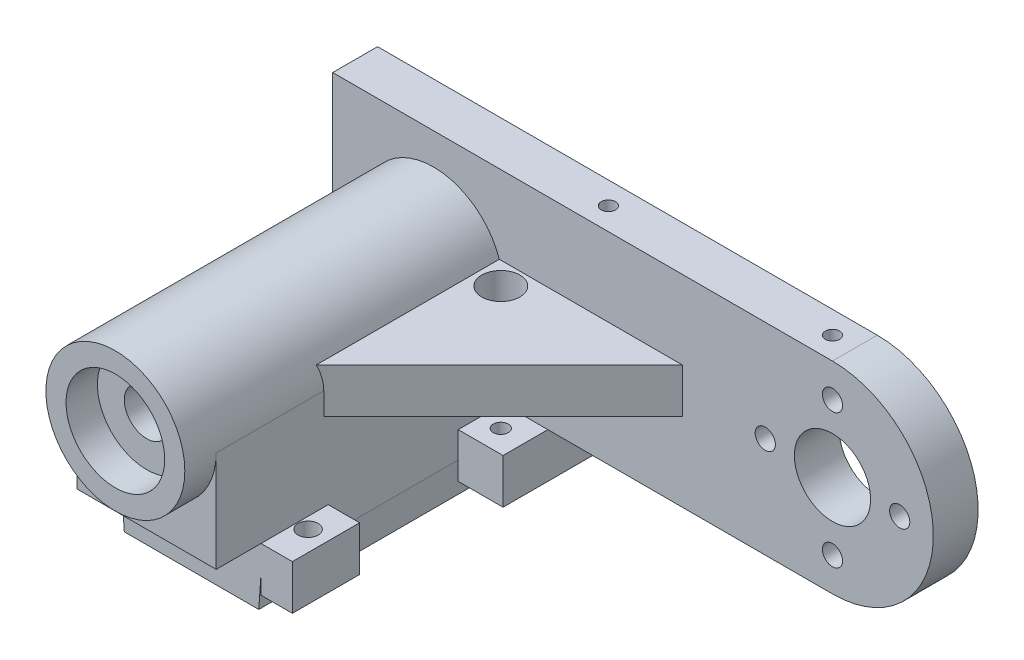
from build123d import *

# Parameters (mm, degrees)
SKETCH1_W                = 26
SKETCH1_H                = 53
SKETCH1_W_2              = 20
SKETCH1_H_2              = 10
BOSS_EXTRUDE1_DEPTH      = 5
SKETCH2_W                = 31
SKETCH2_H                = 59
SKETCH2_W_2              = 26
SKETCH2_H_2              = 53
BOSS_EXTRUDE2_DEPTH      = 10
SKETCH3_W                = 31
SKETCH3_H                = 59
BOSS_EXTRUDE3_DEPTH      = 3
CHAMFER1_SIZE            = 0.5
CHAMFER1_SIZE2           = 7.150333128
SKETCH10_W               = 7
SKETCH10_H               = 15
SKETCH10_R               = 2.25
BOSS_EXTRUDE7_DEPTH      = 10
SKETCH11_W               = 7
SKETCH11_H               = 3
CUT_EXTRUDE4_DEPTH       = 10
CHAMFER2_SIZE            = 2
CHAMFER2_SIZE2           = 4.100607683
BOSS_EXTRUDE8_REACH      = 69.567
SKETCH12_W               = 10
SKETCH12_H               = 15
SKETCH12_R               = 1.676379865
BOSS_EXTRUDE9_START      = -56
SKETCH15_R               = 8.5
SKETCH15_R_2             = 2.25
SKETCH15_R_3             = 11
BOSS_EXTRUDE9_DEPTH      = 5
BOSS_EXTRUDE9_DEPTH_BACK = 5
SKETCH16_R               = 2.25
SKETCH16_R_2             = 8.5
SKETCH16_R_3             = 5
BOSS_EXTRUDE10_DEPTH     = 2
SKETCH17_R               = 5
BOSS_EXTRUDE11_DEPTH     = 64
RIB2_REACH               = 123.175
SKETCH20_WALL_W          = 300.919527638
SKETCH20_WALL_H          = 10
BOSS_EXTRUDE12_DEPTH     = 5
SKETCH22_R               = 15.5
SKETCH22_R_2             = 11
BOSS_EXTRUDE13_DEPTH     = 7
SKETCH23_R               = 4.25
CUT_EXTRUDE5_DEPTH       = 29
SKETCH24_R               = 1.6
CUT_EXTRUDE6_DEPTH       = 8
SKETCH25_R               = 1.6
CUT_EXTRUDE7_DEPTH       = 8


with BuildPart() as part:
    # Sketch1 → Boss-Extrude1 (new body)
    with BuildSketch(Plane(origin=(0, 0, 0), x_dir=(1, 0, 0), z_dir=(0, 1, 0))):
        with Locations((-13, 26.5)):
            Rectangle(SKETCH1_W, SKETCH1_H)
        with Locations((-13, 27)):
            Rectangle(SKETCH1_W_2, SKETCH1_H_2, mode=Mode.SUBTRACT)
        with Locations((-13, 43)):
            Rectangle(SKETCH1_W_2, SKETCH1_H_2, mode=Mode.SUBTRACT)
        with Locations((-13, 11)):
            Rectangle(SKETCH1_W_2, SKETCH1_H_2, mode=Mode.SUBTRACT)
    extrude(amount=BOSS_EXTRUDE1_DEPTH)

    # Sketch2 → Boss-Extrude2 (add)
    with BuildSketch(Plane(origin=(0, 5, 0), x_dir=(1, 0, 0), z_dir=(0, 1, 0))):
        with Locations((-13, 26.5)):
            Rectangle(SKETCH2_W, SKETCH2_H)
        with Locations((-13, 26.5)):
            Rectangle(SKETCH2_W_2, SKETCH2_H_2, mode=Mode.SUBTRACT)
    extrude(amount=-BOSS_EXTRUDE2_DEPTH)

    # Sketch3 → Boss-Extrude3 (add)
    with BuildSketch(Plane(origin=(0, 5, 0), x_dir=(1, 0, 0), z_dir=(0, 1, 0))):
        with Locations((-13, 26.5)):
            Rectangle(SKETCH3_W, SKETCH3_H)
    extrude(amount=BOSS_EXTRUDE3_DEPTH)

    # Chamfer1
    chamfer1_edges = [part.edges().sort_by_distance(p)[0] for p in [
        (-28.5, -5, -26.5),
        (2.5, -5, -26.5),
    ]]
    chamfer1_side = [part.faces().sort_by_distance(p)[0] for p in [
        (-13, -5, -55.333516692),
    ]]
    chamfer(chamfer1_edges, length=CHAMFER1_SIZE, length2=CHAMFER1_SIZE2, reference=chamfer1_side[0])

    # Sketch10 → Boss-Extrude7 (add)
    with BuildSketch(Plane(origin=(0, 8, 0), x_dir=(1, 0, 0), z_dir=(0, 1, 0))):
        with Locations((6, 4.5)):
            Rectangle(SKETCH10_W, SKETCH10_H)
        with Locations(Location((5, 5, 0), (0, 0, 270))):
            Circle(SKETCH10_R, mode=Mode.SUBTRACT)
        with Locations((-32, 4.5)):
            Rectangle(SKETCH10_W, SKETCH10_H)
        with Locations(Location((-31, 5, 0), (0, 0, 90))):
            Circle(SKETCH10_R, mode=Mode.SUBTRACT)
    extrude(amount=-BOSS_EXTRUDE7_DEPTH)

    # Sketch11 → Cut-Extrude4 (cut)
    with BuildSketch(Plane(origin=(0, 8, 0), x_dir=(1, 0, 0), z_dir=(0, 1, 0))):
        with Locations((-32, 10.5)):
            Rectangle(SKETCH11_W, SKETCH11_H)
    extrude(amount=-CUT_EXTRUDE4_DEPTH, mode=Mode.SUBTRACT)

    # Chamfer2
    chamfer2_edges = [part.edges().sort_by_distance(p)[0] for p in [
        (-35.5, 3, -9),
    ]]
    chamfer2_side = [part.faces().sort_by_distance(p)[0] for p in [
        (-35.5, 3, -3),
    ]]
    chamfer(chamfer2_edges, length=CHAMFER2_SIZE, length2=CHAMFER2_SIZE2, reference=chamfer2_side[0])

    # Boss-Extrude8: up to this face of the body (flat: up to its plane)
    boss_extrude8_end = Plane(part.part.faces().sort_by_distance((6, -2, 2.834470546))[0])
    # Sketch12 → Boss-Extrude8 (add, up to the picked face)
    with BuildSketch(Plane(origin=(0, 8, 0), x_dir=(1, 0, 0), z_dir=(0, 1, 0)), mode=Mode.PRIVATE) as boss_extrude8_sk1:
        with Locations((7.5, 48.5)):
            Rectangle(SKETCH12_W, SKETCH12_H)
        with Locations(Location((7, 46, 0), (0, 0, 270))):
            Circle(SKETCH12_R, mode=Mode.SUBTRACT)
    boss_extrude8_tool1 = split(extrude(boss_extrude8_sk1.sketch, amount=-BOSS_EXTRUDE8_REACH, mode=Mode.PRIVATE), bisect_by=boss_extrude8_end, keep=Keep.BOTH, mode=Mode.PRIVATE)
    # Sketch12 → Boss-Extrude8 (add, up to the picked face)
    with BuildSketch(Plane(origin=(0, 8, 0), x_dir=(1, 0, 0), z_dir=(0, 1, 0)), mode=Mode.PRIVATE) as boss_extrude8_sk2:
        with Locations((-33.5, 48.5)):
            Rectangle(SKETCH12_W, SKETCH12_H)
        with Locations(Location((-33, 46, 0), (0, 0, 270))):
            Circle(SKETCH12_R, mode=Mode.SUBTRACT)
    boss_extrude8_tool2 = split(extrude(boss_extrude8_sk2.sketch, amount=-BOSS_EXTRUDE8_REACH, mode=Mode.PRIVATE), bisect_by=boss_extrude8_end, keep=Keep.BOTH, mode=Mode.PRIVATE)
    add(boss_extrude8_tool1.solids().sort_by(Axis((7.531269, 8, -48.656347), (0, -1, 0)))[0])
    add(boss_extrude8_tool2.solids().sort_by(Axis((-33.531269, 8, -48.656347), (0, -1, 0)))[0])

    # Sketch15 → Boss-Extrude9 (add, two sides)
    with BuildSketch(Plane.XY.offset(BOSS_EXTRUDE9_START)) as boss_extrude9_sk:
        with BuildLine():
            Line((-13, 53), (76, 53))
            ThreePointArc((76, 53), (98.5, 30.5), (76, 8))
            Line((76, 8), (-13, 8))
            Line((-13, 8), (-35.5, 8))
            Line((-35.5, 8), (-35.5, 53))
            Line((-35.5, 53), (-13, 53))
        make_face()
        with Locations(Location((76, 30.5, 0), (0, 0, 180))):
            Circle(SKETCH15_R, mode=Mode.SUBTRACT)
        with Locations(Location((76, 45.5, 0), (0, 0, 180))):
            Circle(SKETCH15_R_2, mode=Mode.SUBTRACT)
        with Locations(Location((76, 15.5, 0), (0, 0, 180))):
            Circle(SKETCH15_R_2, mode=Mode.SUBTRACT)
        with Locations(Location((91, 30.5, 0), (0, 0, 180))):
            Circle(SKETCH15_R_2, mode=Mode.SUBTRACT)
        with Locations(Location((61, 30.5, 0), (0, 0, 180))):
            Circle(SKETCH15_R_2, mode=Mode.SUBTRACT)
        with Locations(Location((-13, 30.5, 0), (0, 0, 180))):
            Circle(SKETCH15_R_3, mode=Mode.SUBTRACT)
    extrude(amount=BOSS_EXTRUDE9_DEPTH)
    extrude(boss_extrude9_sk.sketch, amount=-BOSS_EXTRUDE9_DEPTH_BACK)

    # Sketch16 → Boss-Extrude10 (add)
    with BuildSketch(Plane.XY.offset(-51)):
        with BuildLine():
            Line((-35.5, 53), (-35.5, 8))
            Line((-35.5, 8), (12.5, 8))
            Line((12.5, 8), (76, 8))
            ThreePointArc((76, 8), (98.5, 30.5), (76, 53))
            Line((76, 53), (-35.5, 53))
        make_face()
        with Locations(Location((76, 45.5, 0), (0, 0, 180))):
            Circle(SKETCH16_R, mode=Mode.SUBTRACT)
        with Locations(Location((91, 30.5, 0), (0, 0, 180))):
            Circle(SKETCH16_R, mode=Mode.SUBTRACT)
        with Locations(Location((76, 15.5, 0), (0, 0, 180))):
            Circle(SKETCH16_R, mode=Mode.SUBTRACT)
        with Locations(Location((76, 30.5, 0), (0, 0, 180))):
            Circle(SKETCH16_R_2, mode=Mode.SUBTRACT)
        with Locations(Location((61, 30.5, 0), (0, 0, 180))):
            Circle(SKETCH16_R, mode=Mode.SUBTRACT)
        with Locations((-13, 30.5)):
            Circle(SKETCH16_R_3, mode=Mode.SUBTRACT)
    extrude(amount=-BOSS_EXTRUDE10_DEPTH)

    # Sketch17 → Boss-Extrude11 (add)
    with BuildSketch(Plane.XY.offset(-51)):
        with BuildLine():
            Line((-28.5, 30.5), (-28.5, 8))
            Line((-28.5, 8), (2.5, 8))
            Line((2.5, 8), (2.5, 30.5))
            ThreePointArc((2.5, 30.5), (-13, 46), (-28.5, 30.5))
        make_face()
        with Locations((-13, 30.5)):
            Circle(SKETCH17_R, mode=Mode.SUBTRACT)
    extrude(amount=BOSS_EXTRUDE11_DEPTH)

    # Sketch20 wall → Rib2 (add, up to next)
    with BuildSketch(Plane(origin=(22.5, 30.5, -31), x_dir=(-0.707106781187, 0, 0.707106781187), z_dir=(0.707106781187, 0, 0.707106781187)), mode=Mode.PRIVATE) as rib2_sk1:
        Rectangle(SKETCH20_WALL_W, SKETCH20_WALL_H)
    rib2_tool1 = extrude(rib2_sk1.sketch, amount=-RIB2_REACH, mode=Mode.PRIVATE) - part.part
    add(rib2_tool1.solids().sort_by_distance((22.5, 30.5, -31))[0])

    # Sketch21 → Boss-Extrude12 (add)
    with BuildSketch(Plane(origin=(0, 0, -56), x_dir=(-1, 0, 0), z_dir=(0, 0, -1))):
        Polygon((-2, -5), (28, -5), (28.5, 2.150333128), (28.5, -2), (38.5, -2), (38.5, 8), (35.5, 8), (-12.5, 8), (-12.5, -2), (-2.5, -2), (-2.5, 2.150333128), align=None)
    extrude(amount=BOSS_EXTRUDE12_DEPTH)

    # Sketch22 → Boss-Extrude13 (add)
    with BuildSketch(Plane.XY.offset(13)):
        with Locations((-13, 30.5)):
            Circle(SKETCH22_R)
        with Locations((-13, 30.5)):
            Circle(SKETCH22_R_2, mode=Mode.SUBTRACT)
    extrude(amount=BOSS_EXTRUDE13_DEPTH)

    # Sketch23 → Cut-Extrude5 (cut)
    with BuildSketch(Plane(origin=(0, 8, 0), x_dir=(1, 0, 0), z_dir=(0, 1, 0))):
        with Locations(Location((7, 46, 0), (0, 0, 270))):
            Circle(SKETCH23_R)
    extrude(amount=CUT_EXTRUDE5_DEPTH, mode=Mode.SUBTRACT)

    # Sketch24 → Cut-Extrude6 (cut)
    with BuildSketch(Plane.ZY.offset(35.5)):
        with Locations((-56, 28)):
            Circle(SKETCH24_R)
        with Locations((-56, 43)):
            Circle(SKETCH24_R)
    extrude(amount=-CUT_EXTRUDE6_DEPTH, mode=Mode.SUBTRACT)

    # Sketch25 → Cut-Extrude7 (cut)
    with BuildSketch(Plane(origin=(0, 53, 0), x_dir=(1, 0, 0), z_dir=(0, 1, 0))):
        with Locations(Location((71, 56, 0), (0, 0, 270))):
            Circle(SKETCH25_R)
        with Locations(Location((21, 56, 0), (0, 0, 270))):
            Circle(SKETCH25_R)
    extrude(amount=-CUT_EXTRUDE7_DEPTH, mode=Mode.SUBTRACT)


solid = part.part
